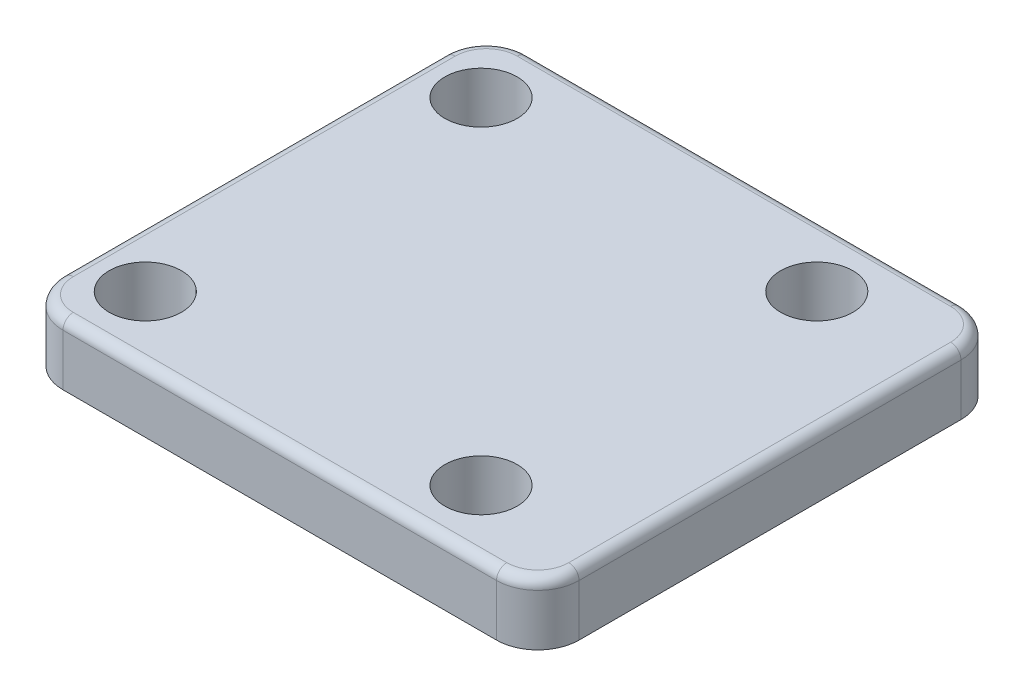
from build123d import *

# Parameters (mm, degrees)
SKETCH1_W           = 50
SKETCH1_H           = 45
BODY_DEPTH          = 6
SKETCH4_R           = 16
ROUND_2_DEPTH       = 2
F_1X45_CHAMFER_SIZE = 1
SKETCH5_R           = 3.5
HOLE_1_DEPTH        = 7
HOLES_2_4_COUNT     = 4
R4_FILLETS_R        = 4
R1_FILLET_R         = 1


with BuildPart() as part:
    # Sketch1 → Body (new body)
    with BuildSketch(Plane(origin=(0, 0, 0), x_dir=(1, 0, 0), z_dir=(0, 1, 0))):
        with Locations((3, 0)):
            Rectangle(SKETCH1_W, SKETCH1_H)
    extrude(amount=BODY_DEPTH)

    # Sketch4 → Round 2 (add)
    with BuildSketch(Plane.XZ):
        Circle(SKETCH4_R)
    extrude(amount=ROUND_2_DEPTH)

    # 1x45 Chamfer
    f_1x45_chamfer_edges = [part.edges().sort_by_distance(p)[0] for p in [
        (-16, -2, 0),
    ]]
    chamfer(f_1x45_chamfer_edges, length=F_1X45_CHAMFER_SIZE)

    # Sketch5 → Hole 1 (cut, through all)
    with BuildSketch(Plane.XZ):
        with Locations((16.263455967, 16.263455967)):
            Circle(SKETCH5_R)
    hole_1 = extrude(amount=-HOLE_1_DEPTH, mode=Mode.SUBTRACT)

    # Holes 2-4: Hole 1 ×4 about axis
    holes_2_4_axis = Axis((0, 0, 0), (0, 1, 0))
    for i in range(1, HOLES_2_4_COUNT):
        add(hole_1.rotate(holes_2_4_axis, i * 360 / HOLES_2_4_COUNT), mode=Mode.SUBTRACT)

    # R4 Fillets
    r4_fillets_edges = [part.edges().sort_by_distance(p)[0] for p in [
        (-22, 3, -22.5),
        (28, 3, -22.5),
        (28, 3, 22.5),
        (-22, 3, 22.5),
    ]]
    fillet(r4_fillets_edges, radius=R4_FILLETS_R)

    # R1 Fillet
    r1_fillet_edges = [part.edges().sort_by_distance(p)[0] for p in [
        (-22, 6, 0),
        (3, 6, -22.5),
        (3, 6, 22.5),
        (28, 6, 0),
        (26.828427125, 6, 21.328427125),
        (-20.828427125, 6, 21.328427125),
        (26.828427125, 6, -21.328427125),
        (-20.828427125, 6, -21.328427125),
    ]]
    fillet(r1_fillet_edges, radius=R1_FILLET_R)


solid = part.part
